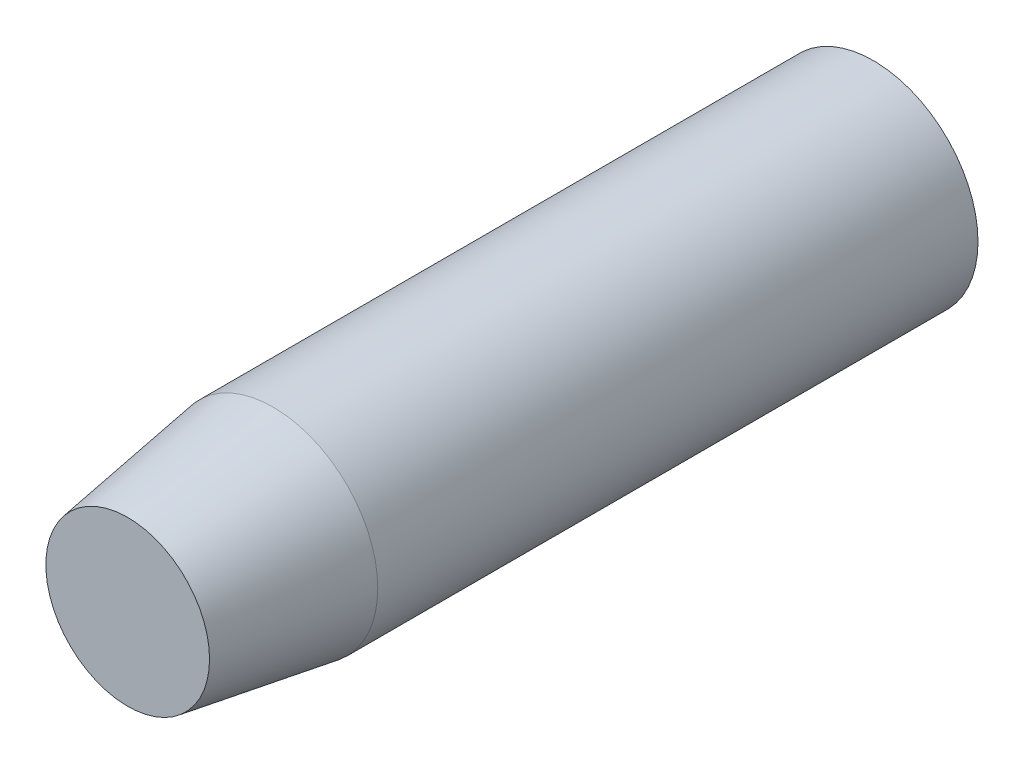
from build123d import *

# Parameters (mm, degrees)
SKETCH1_R           = 18.25625
BOSS_EXTRUDE1_DEPTH = 65.0875
CHAMFER1_SIZE       = 25.4
CHAMFER1_SIZE2      = 3.96875


with BuildPart() as part:
    # Sketch1 → Boss-Extrude1 (new body, symmetric)
    with BuildSketch(Plane.XY):
        Circle(SKETCH1_R)
    extrude(amount=BOSS_EXTRUDE1_DEPTH, both=True)

    # Chamfer1
    chamfer1_edges = [part.edges().sort_by_distance(p)[0] for p in [
        (-18.25625, 0, 65.0875),
    ]]
    chamfer1_side = [part.faces().sort_by_distance(p)[0] for p in [
        (-18.25625, 0, 0),
    ]]
    chamfer(chamfer1_edges, length=CHAMFER1_SIZE, length2=CHAMFER1_SIZE2, reference=chamfer1_side[0])


solid = part.part
